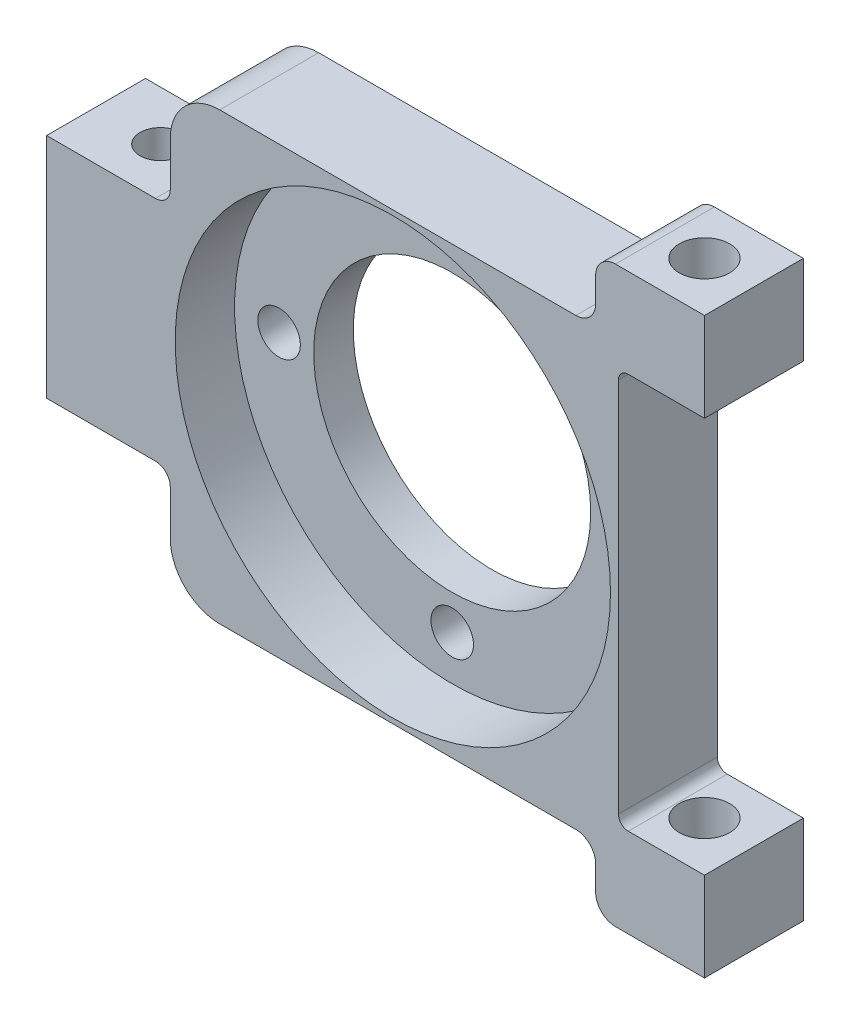
from build123d import *

# Parameters (mm, degrees)
SKETCH_1_W               = 70
SKETCH_1_H               = 58
SKETCH_1_R               = 2.15
SKETCH_1_R_2             = 14
EXTRUDE_1_DEPTH          = 10
SKETCH_2_R               = 22
CUT_EXTRUDE_1_DEPTH      = 6
SKETCH_3_R               = 2.55
CUT_EXTRUDE_2_DEPTH      = 1
CUT_EXTRUDE_2_DEPTH_BACK = 59
SKETCH_4_R               = 2.05
CUT_EXTRUDE_3_DEPTH      = 1
CUT_EXTRUDE_3_DEPTH_BACK = 59
SKETCH_6_W               = 12.5
SKETCH_6_H               = 17.5
CUT_EXTRUDE_4_DEPTH      = 11
FILLET_1_R               = 1.5
SKETCH_7_W               = 3.5
SKETCH_7_H               = 10
CUT_EXTRUDE_5_DEPTH      = 1
CUT_EXTRUDE_5_DEPTH_BACK = 59
SKETCH_8_W               = 8.7
SKETCH_8_H               = 40
CUT_EXTRUDE_6_DEPTH      = 11
FILLET_3_R               = 1
SKETCH_9_W               = 43
SKETCH_9_H               = 6.5
CUT_EXTRUDE_7_DEPTH      = 11
FILLET_4_R               = 5
FILLET_5_R               = 2


with BuildPart() as part:
    # 草图1 → 凸台-拉伸1 (new body)
    with BuildSketch(Plane.XY):
        Rectangle(SKETCH_1_W, SKETCH_1_H)
        with Locations((17.5, 0)):
            Circle(SKETCH_1_R, mode=Mode.SUBTRACT)
        with Locations((0, -17.5)):
            Circle(SKETCH_1_R, mode=Mode.SUBTRACT)
        with Locations((-17.5, 0)):
            Circle(SKETCH_1_R, mode=Mode.SUBTRACT)
        with Locations((0, 17.5)):
            Circle(SKETCH_1_R, mode=Mode.SUBTRACT)
        Circle(SKETCH_1_R_2, mode=Mode.SUBTRACT)
    extrude(amount=EXTRUDE_1_DEPTH)

    # 草图2 → 切除-拉伸1 (cut)
    with BuildSketch(Plane.XY.offset(10)):
        Circle(SKETCH_2_R)
    extrude(amount=-CUT_EXTRUDE_1_DEPTH, mode=Mode.SUBTRACT)

    # 草图3 → 切除-拉伸2 (cut, two sides)
    with BuildSketch(Plane(origin=(0, 29, 0), x_dir=(1, 0, 0), z_dir=(0, 1, 0))) as cut_extrude_2_sk:
        with Locations((26.5, -5)):
            Circle(SKETCH_3_R)
    extrude(amount=CUT_EXTRUDE_2_DEPTH, mode=Mode.SUBTRACT)
    extrude(cut_extrude_2_sk.sketch, amount=-CUT_EXTRUDE_2_DEPTH_BACK, mode=Mode.SUBTRACT)

    # 草图4 → 切除-拉伸3 (cut, two sides)
    with BuildSketch(Plane(origin=(0, 29, 0), x_dir=(1, 0, 0), z_dir=(0, 1, 0))) as cut_extrude_3_sk:
        with Locations((-28.5, -5)):
            Circle(SKETCH_4_R)
    extrude(amount=CUT_EXTRUDE_3_DEPTH, mode=Mode.SUBTRACT)
    extrude(cut_extrude_3_sk.sketch, amount=-CUT_EXTRUDE_3_DEPTH_BACK, mode=Mode.SUBTRACT)

    # 草图6 → 切除-拉伸4 (cut, through all)
    with BuildSketch(Plane(origin=(0, 0, 0), x_dir=(-1, 0, 0), z_dir=(0, 0, -1))):
        with Locations((28.75, 20.25)):
            Rectangle(SKETCH_6_W, SKETCH_6_H)
        with Locations((28.75, -20.25)):
            Rectangle(SKETCH_6_W, SKETCH_6_H)
    extrude(amount=-CUT_EXTRUDE_4_DEPTH, mode=Mode.SUBTRACT)

    # 圆角1
    fillet_1_edges = [part.edges().sort_by_distance(p)[0] for p in [
        (-22.5, 11.5, 5),
        (-22.5, -11.5, 5),
    ]]
    fillet(fillet_1_edges, radius=FILLET_1_R)

    # 草图7 → 切除-拉伸5 (cut, two sides)
    with BuildSketch(Plane(origin=(0, 29, 0), x_dir=(1, 0, 0), z_dir=(0, 1, 0))) as cut_extrude_5_sk:
        with Locations((33.25, -5)):
            Rectangle(SKETCH_7_W, SKETCH_7_H)
    extrude(amount=CUT_EXTRUDE_5_DEPTH, mode=Mode.SUBTRACT)
    extrude(cut_extrude_5_sk.sketch, amount=-CUT_EXTRUDE_5_DEPTH_BACK, mode=Mode.SUBTRACT)

    # 草图8 → 切除-拉伸6 (cut, through all)
    with BuildSketch(Plane.XY.offset(10)):
        with Locations((27.15, 0)):
            Rectangle(SKETCH_8_W, SKETCH_8_H)
    extrude(amount=-CUT_EXTRUDE_6_DEPTH, mode=Mode.SUBTRACT)

    # 圆角3
    fillet_3_edges = [part.edges().sort_by_distance(p)[0] for p in [
        (22.8, 20, 5),
        (22.8, -20, 5),
    ]]
    fillet(fillet_3_edges, radius=FILLET_3_R)

    # 草图9 → 切除-拉伸7 (cut, through all)
    with BuildSketch(Plane.XY.offset(10)):
        with Locations((-1, -25.75)):
            Rectangle(SKETCH_9_W, SKETCH_9_H)
        with Locations((-1, 25.75)):
            Rectangle(SKETCH_9_W, SKETCH_9_H)
    extrude(amount=-CUT_EXTRUDE_7_DEPTH, mode=Mode.SUBTRACT)

    # 圆角4
    fillet_4_edges = [part.edges().sort_by_distance(p)[0] for p in [
        (-22.5, -22.5, 5),
        (-22.5, 22.5, 5),
    ]]
    fillet(fillet_4_edges, radius=FILLET_4_R)

    # 圆角5
    fillet_5_edges = [part.edges().sort_by_distance(p)[0] for p in [
        (20.5, -22.5, 5),
        (20.5, -29, 5),
        (20.5, 29, 5),
        (20.5, 22.5, 5),
    ]]
    fillet(fillet_5_edges, radius=FILLET_5_R)


solid = part.part
